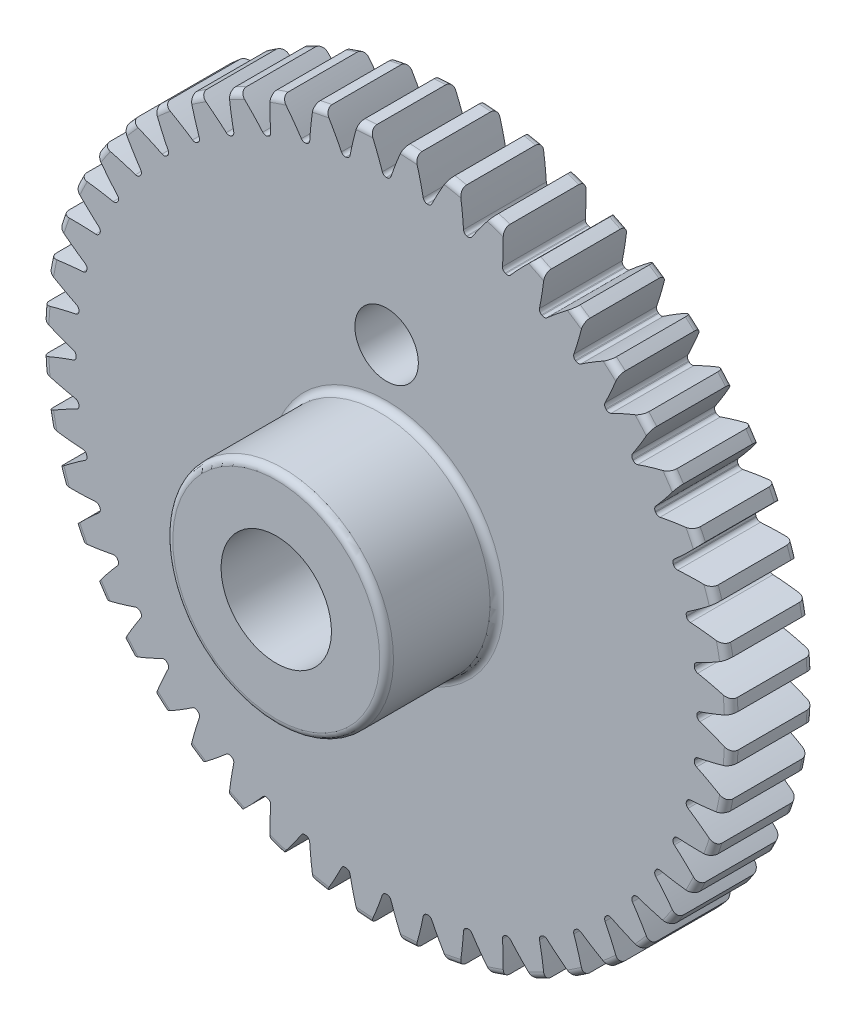
from build123d import *

# Parameters (mm, degrees)
FILLET2_R          = 0.5
CUT_EXTRUDE2_DEPTH = 37.24913799
CIRPATTERN1_COUNT  = 48
SKETCH8_R          = 2.3
CUT_EXTRUDE3_DEPTH = 38.988044387


with BuildPart() as part:
    # Sketch4 → Revolve1 (revolve)
    with BuildSketch(Plane(origin=(0, 0, 0), x_dir=(0, 0, -1), z_dir=(1, 0, 0))):
        Polygon((-14, 4), (-14, 8), (-6, 8), (-6, 25), (0, 25), (0, 4), align=None)
    revolve(axis=Axis((0, 0, 6), (0, 0, 1)))

    # Fillet2
    fillet2_edges = [part.edges().sort_by_distance(p)[0] for p in [
        (0, -8, 14),
        (0, -8, 6),
        (0, -25, 6),
        (0, -25, 0),
    ]]
    fillet(fillet2_edges, radius=FILLET2_R)

    # Sketch7 → Cut-Extrude2 (cut, through all)
    with BuildSketch(Plane.XY.offset(6)):
        with BuildLine():
            ThreePointArc((-0.027461051, 22.499983242), (0, 22.5), (0.027461051, 22.499983242))
            ThreePointArc((0.027461051, 22.499983242), (0.202731788, 22.556239605), (0.312161304, 22.704259166))
            ThreePointArc((0.312161304, 22.704259166), (0.730259175, 23.848927802), (1.205921567, 24.970898125))
            ThreePointArc((1.205921567, 24.970898125), (0, 25), (-1.205921567, 24.970898125))
            ThreePointArc((-1.205921567, 24.970898125), (-0.730259175, 23.848927802), (-0.312161304, 22.704259166))
            ThreePointArc((-0.312161304, 22.704259166), (-0.202731788, 22.556239605), (-0.027461051, 22.499983242))
        make_face()
    cut_extrude2 = extrude(amount=-CUT_EXTRUDE2_DEPTH, mode=Mode.SUBTRACT)

    # CirPattern1: Cut-Extrude2 ×48 about axis
    cirpattern1_axis = Axis((0, 0, 14), (0, 0, -1))
    for i in range(1, CIRPATTERN1_COUNT):
        add(cut_extrude2.rotate(cirpattern1_axis, i * 360 / CIRPATTERN1_COUNT), mode=Mode.SUBTRACT)

    # Sketch8 → Cut-Extrude3 (cut, through all)
    with BuildSketch(Plane(origin=(0, 0, 0), x_dir=(-1, 0, 0), z_dir=(0, 0, -1))):
        with Locations((0, 12)):
            Circle(SKETCH8_R)
    extrude(amount=-CUT_EXTRUDE3_DEPTH, mode=Mode.SUBTRACT)


solid = part.part
